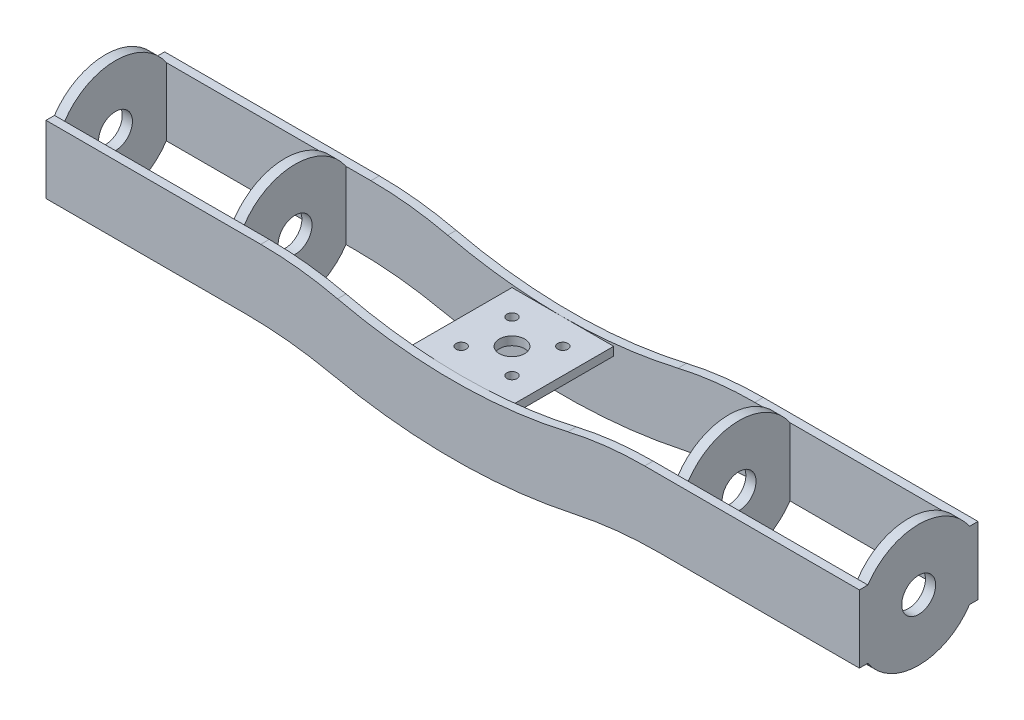
from build123d import *

# Parameters (mm, degrees)
BOSS_EXTRUDE2_DEPTH     = 2.5
SKETCH2_R               = 5
BOSS_EXTRUDE3_DEPTH     = 3
LPATTERN1_COUNT         = 2
LPATTERN1_PITCH         = 53
MIRROR8_COPY_1_SKETCH_R = 5
MIRROR8_COPY_1_DEPTH    = 3
SKETCH4_W               = 30
SKETCH4_H               = 2.5
BOSS_EXTRUDE4_DEPTH     = 35
SKETCH6_R               = 3.75
SKETCH6_R_2             = 1.5
CUT_EXTRUDE1_DEPTH      = 2.5


with BuildPart() as part:
    # Sketch1 → Boss-Extrude2 (new body)
    with BuildSketch(Plane.XY):
        with BuildLine():
            Line((-120, 0), (-61.0553028, 0))
            ThreePointArc((-61.0553028, 0), (-48.351787131, -0.674308342), (-35.791039572, -2.689655172))
            ThreePointArc((-35.791039572, -2.689655172), (0, -6.5), (35.791039572, -2.689655172))
            ThreePointArc((35.791039572, -2.689655172), (48.351787131, -0.674308342), (61.0553028, 0))
            Line((61.0553028, 0), (120, 0))
            Line((120, 0), (120, 20))
            Line((120, 20), (56.637002039, 20))
            ThreePointArc((56.637002039, 20), (45.235247788, 19.347873656), (33.982201224, 17.4))
            ThreePointArc((33.982201224, 17.4), (0, 13.5), (-33.982201224, 17.4))
            ThreePointArc((-33.982201224, 17.4), (-45.235247788, 19.347873656), (-56.637002039, 20))
            Line((-56.637002039, 20), (-120, 20))
            Line((-120, 20), (-120, 0))
        make_face()
    extrude(amount=BOSS_EXTRUDE2_DEPTH)


with BuildPart() as body_2:
    # Mirror7: mirrored copy
    add(part.part.mirror(Plane.XY.offset(-15)))


with BuildPart() as part_1:
    add(part.part)

    add(body_2.part)  # Boss-Extrude3 merges body 2
    # Sketch2 → Boss-Extrude3 (add)
    with BuildSketch(Plane(origin=(120, 0, 0), x_dir=(0, 0, -1), z_dir=(1, 0, 0))):
        with BuildLine():
            Line((0, 20), (0, 0))
            ThreePointArc((0, 0), (15, -8.027756377), (30, 0))
            Line((30, 0), (30, 20))
            ThreePointArc((30, 20), (15, 28.027756377), (0, 20))
        make_face()
        with Locations((15, 10)):
            Circle(SKETCH2_R, mode=Mode.SUBTRACT)
    boss_extrude3 = extrude(amount=-BOSS_EXTRUDE3_DEPTH)

    # LPattern1: Boss-Extrude3 ×2
    with Locations(*[(-i * LPATTERN1_PITCH, 0, 0) for i in range(1, LPATTERN1_COUNT)]):
        add(boss_extrude3)

    # Mirror8: Boss-Extrude3 across plane
    add(boss_extrude3.mirror(Plane(origin=(0, 0, 0), x_dir=(0, 0, 1), z_dir=(1, 0, 0))))

    # Mirror8 copy 1 sketch → Mirror8 copy 1 (add)
    with BuildSketch(Plane(origin=(-67, 0, 0), x_dir=(0, 0, -1), z_dir=(-1, 0, 0))):
        with BuildLine():
            Line((0, -20), (0, 0))
            ThreePointArc((0, 0), (15, 8.027756377), (30, 0))
            Line((30, 0), (30, -20))
            ThreePointArc((30, -20), (15, -28.027756377), (0, -20))
        make_face()
        with Locations((15, -10)):
            Circle(MIRROR8_COPY_1_SKETCH_R, mode=Mode.SUBTRACT)
    extrude(amount=-MIRROR8_COPY_1_DEPTH)

    # Sketch4 → Boss-Extrude4 (add)
    with BuildSketch(Plane(origin=(0, 0, -32.5), x_dir=(-1, 0, 0), z_dir=(0, 0, -1))):
        with Locations((0, 12.25)):
            Rectangle(SKETCH4_W, SKETCH4_H)
    extrude(amount=-BOSS_EXTRUDE4_DEPTH)

    # Sketch6 → Cut-Extrude1 (cut)
    with BuildSketch(Plane(origin=(0, 13.5, 0), x_dir=(1, 0, 0), z_dir=(0, 1, 0))):
        with Locations((0, 15)):
            Circle(SKETCH6_R)
        with Locations((-7.5, 22.5)):
            Circle(SKETCH6_R_2)
        with Locations((7.5, 22.5)):
            Circle(SKETCH6_R_2)
        with Locations((7.5, 7.5)):
            Circle(SKETCH6_R_2)
        with Locations((-7.5, 7.5)):
            Circle(SKETCH6_R_2)
    extrude(amount=-CUT_EXTRUDE1_DEPTH, mode=Mode.SUBTRACT)


solid = part_1.part
